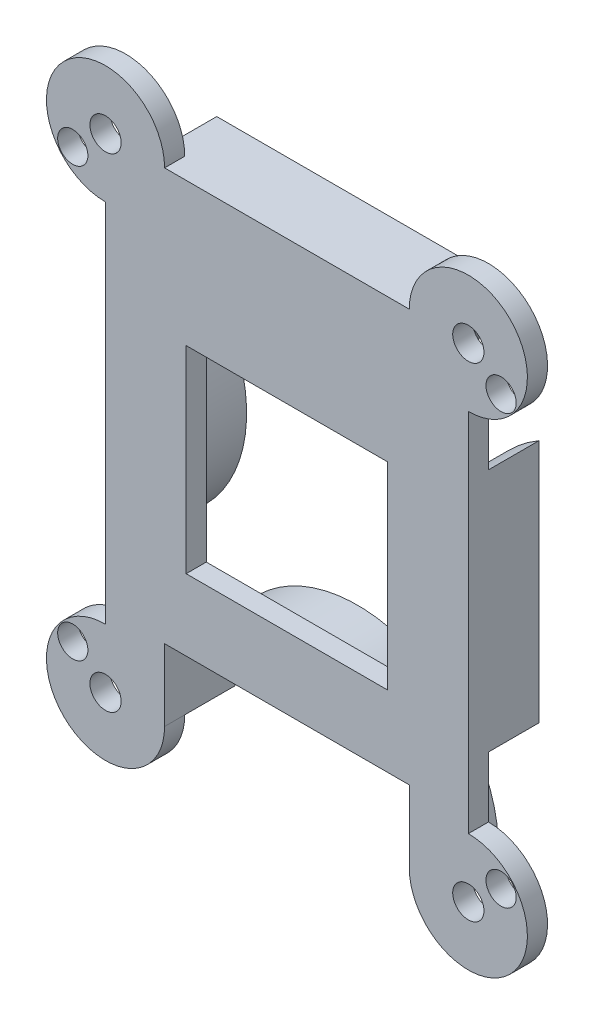
from build123d import *

# Parameters (mm, degrees)
EXTRUDE_1_DEPTH     = 5
EXTRUDE_1_2_DEPTH   = 5
EXTRUDE_1_3_DEPTH   = 5
EXTRUDE_1_4_DEPTH   = 5
EXTRUDE_3_DEPTH     = 2
SKETCH_3_W          = 20
SKETCH_3_H          = 19.604409946
CUT_EXTRUDE_1_DEPTH = 2
SKETCH_4_R          = 1.5
CUT_EXTRUDE_2_DEPTH = 12
SKETCH_6_W          = 24.27884079
SKETCH_6_H          = 14.237664084
CUT_EXTRUDE_5_DEPTH = 10


with BuildPart() as part:
    # 草图1 → 凸台-拉伸1 (new body)
    with BuildSketch(Plane.XY):
        with BuildLine():
            Line((13.964240044, 24), (-13.964240044, 24))
            ThreePointArc((-13.964240044, 24), (0, 11), (13.964240044, 24))
        make_face()
    extrude(amount=-EXTRUDE_1_DEPTH)



with BuildPart() as body_2:
    # 草图1 → Extrude 1 2 (new body)
    with BuildSketch(Plane.XY):
        with BuildLine():
            ThreePointArc((-18, -12.124355653), (-11, 0), (-18, 12.124355653))
            Line((-18, 12.124355653), (-18, -12.124355653))
        make_face()
    extrude(amount=-EXTRUDE_1_2_DEPTH)


with BuildPart() as body_3:
    # 草图1 → Extrude 1 3 (new body)
    with BuildSketch(Plane.XY):
        with BuildLine():
            Line((18, -12.124355653), (18, 12.124355653))
            ThreePointArc((18, 12.124355653), (11, 0), (18, -12.124355653))
        make_face()
    extrude(amount=-EXTRUDE_1_3_DEPTH)


with BuildPart() as body_4:
    # 草图1 → Extrude 1 4 (new body)
    with BuildSketch(Plane.XY):
        with BuildLine():
            ThreePointArc((13.964240044, -24), (0, -11), (-13.964240044, -24))
            Line((-13.964240044, -24), (13.964240044, -24))
        make_face()
    extrude(amount=-EXTRUDE_1_4_DEPTH)


with BuildPart() as part_1:
    add(part.part)

    add(body_2.part)  # 凸台-拉伸3 merges body 2

    add(body_3.part)  # 凸台-拉伸3 merges body 3

    add(body_4.part)  # 凸台-拉伸3 merges body 4
    # 草图2 → 凸台-拉伸3 (add)
    with BuildSketch(Plane.XY):
        with BuildLine():
            ThreePointArc((-18, 22.45), (-19.096015511, 25.096015511), (-16.45, 24))
            Line((-16.45, 24), (-12.139420395, 24))
            ThreePointArc((-12.139420395, 24), (-22.14405558, 28.14405558), (-18, 18.139420395))
            Line((-18, 18.139420395), (-18, 22.45))
        make_face()
        with BuildLine():
            Line((-12.139420395, 24), (-16.45, 24))
            ThreePointArc((-16.45, 24), (-16.903984489, 22.903984489), (-18, 22.45))
            Line((-18, 22.45), (-18, 18.139420395))
            ThreePointArc((-18, 18.139420395), (-13.85594442, 19.85594442), (-12.139420395, 24))
        make_face()
        with BuildLine():
            Line((12.139420395, 24), (-12.139420395, 24))
            ThreePointArc((-12.139420395, 24), (-13.85594442, 19.85594442), (-18, 18.139420395))
            Line((-18, 18.139420395), (-18, 12.124355653))
            ThreePointArc((-18, 12.124355653), (-11, 0), (-18, -12.124355653))
            Line((-18, -12.124355653), (-18, -18.139420395))
            ThreePointArc((-18, -18.139420395), (-13.85594442, -19.85594442), (-12.139420395, -24))
            Line((-12.139420395, -24), (12.139420395, -24))
            ThreePointArc((12.139420395, -24), (13.85594442, -19.85594442), (18, -18.139420395))
            Line((18, -18.139420395), (18, 18.139420395))
            ThreePointArc((18, 18.139420395), (13.85594442, 19.85594442), (12.139420395, 24))
        make_face()
        with BuildLine():
            ThreePointArc((-18, -12.124355653), (-11, 0), (-18, 12.124355653))
            Line((-18, 12.124355653), (-18, -12.124355653))
        make_face()
        with BuildLine():
            ThreePointArc((23.860579605, 24), (18, 29.860579605), (12.139420395, 24))
            Line((12.139420395, 24), (16.45, 24))
            ThreePointArc((16.45, 24), (18, 25.55), (19.55, 24))
            ThreePointArc((19.55, 24), (19.096015511, 22.903984489), (18, 22.45))
            Line((18, 22.45), (18, 18.139420395))
            ThreePointArc((18, 18.139420395), (22.14405558, 19.85594442), (23.860579605, 24))
        make_face()
        with BuildLine():
            Line((16.45, 24), (12.139420395, 24))
            ThreePointArc((12.139420395, 24), (13.85594442, 19.85594442), (18, 18.139420395))
            Line((18, 18.139420395), (18, 22.45))
            ThreePointArc((18, 22.45), (16.903984489, 22.903984489), (16.45, 24))
        make_face()
        with BuildLine():
            ThreePointArc((-12.139420395, -24), (-13.85594442, -19.85594442), (-18, -18.139420395))
            Line((-18, -18.139420395), (-18, -22.45))
            ThreePointArc((-18, -22.45), (-16.903984489, -22.903984489), (-16.45, -24))
            Line((-16.45, -24), (-12.139420395, -24))
        make_face()
        with BuildLine():
            Line((-18, -22.45), (-18, -18.139420395))
            ThreePointArc((-18, -18.139420395), (-22.14405558, -28.14405558), (-12.139420395, -24))
            Line((-12.139420395, -24), (-16.45, -24))
            ThreePointArc((-16.45, -24), (-19.096015511, -25.096015511), (-18, -22.45))
        make_face()
        with BuildLine():
            ThreePointArc((23.860579605, -24), (22.14405558, -19.85594442), (18, -18.139420395))
            Line((18, -18.139420395), (18, -22.45))
            ThreePointArc((18, -22.45), (19.096015511, -22.903984489), (19.55, -24))
            ThreePointArc((19.55, -24), (18, -25.55), (16.45, -24))
            Line((16.45, -24), (12.139420395, -24))
            ThreePointArc((12.139420395, -24), (18, -29.860579605), (23.860579605, -24))
        make_face()
        with BuildLine():
            Line((18, -22.45), (18, -18.139420395))
            ThreePointArc((18, -18.139420395), (13.85594442, -19.85594442), (12.139420395, -24))
            Line((12.139420395, -24), (16.45, -24))
            ThreePointArc((16.45, -24), (16.903984489, -22.903984489), (18, -22.45))
        make_face()
    extrude(amount=EXTRUDE_3_DEPTH)

    # 草图3 → 切除-拉伸1 (cut)
    with BuildSketch(Plane(origin=(0, 0, 0), x_dir=(-1, 0, 0), z_dir=(0, 0, -1))):
        Rectangle(SKETCH_3_W, SKETCH_3_H)
    extrude(amount=-CUT_EXTRUDE_1_DEPTH, mode=Mode.SUBTRACT)

    # 草图4 → 切除-拉伸2 (cut)
    with BuildSketch(Plane(origin=(0, 0, -5), x_dir=(-1, 0, 0), z_dir=(0, 0, -1))):
        with Locations((21.25, -21.25)):
            Circle(SKETCH_4_R)
        with Locations((21.25, 21.25)):
            Circle(SKETCH_4_R)
        with Locations((-21.25, 21.25)):
            Circle(SKETCH_4_R)
        with Locations((-21.25, -21.25)):
            Circle(SKETCH_4_R)
    extrude(amount=-CUT_EXTRUDE_2_DEPTH, mode=Mode.SUBTRACT)

    # 草图6 → 切除-拉伸5 (cut)
    with BuildSketch(Plane.XY.offset(2)):
        with Locations((0, -24)):
            Rectangle(SKETCH_6_W, SKETCH_6_H)
    extrude(amount=-CUT_EXTRUDE_5_DEPTH, mode=Mode.SUBTRACT)


solid = part_1.part
